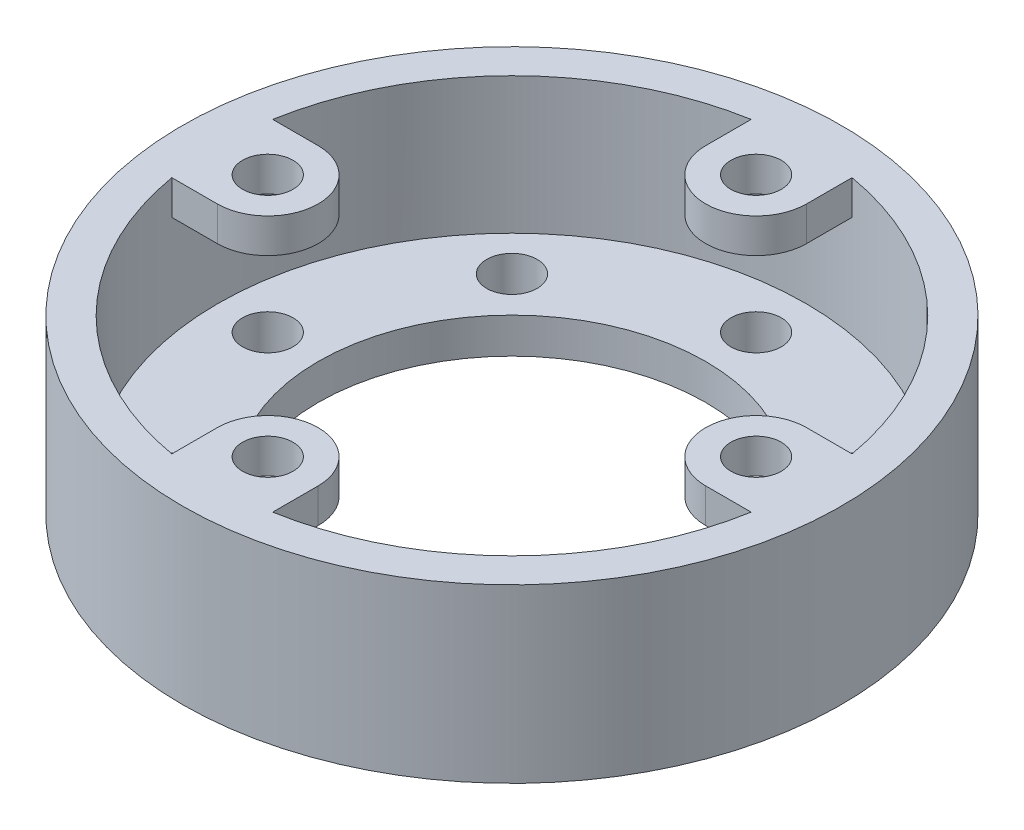
from build123d import *

# Parameters (mm, degrees)
SKETCH1_W           = 7.874
SKETCH1_H           = 38.1
SKETCH2_R           = 65.151
SKETCH2_R_2         = 42.926
BOSS_EXTRUDE2_DEPTH = 7.874
SKETCH4_R           = 5.588
CUT_EXTRUDE1_DEPTH  = 8.874
SKETCH5_R           = 5.588
BOSS_EXTRUDE4_DEPTH = 7.62


with BuildPart() as part:
    # Sketch1 → Revolve1 (revolve)
    with BuildSketch(Plane.XY):
        with Locations((-69.088, 19.05)):
            Rectangle(SKETCH1_W, SKETCH1_H)
    revolve(axis=Axis((0, 92.899450936, 0), (0, -1, 0)))

    # Sketch2 → Boss-Extrude2 (add)
    with BuildSketch(Plane(origin=(0, 0, 0), x_dir=(1, 0, 0), z_dir=(0, 1, 0))):
        Circle(SKETCH2_R)
        Circle(SKETCH2_R_2, mode=Mode.SUBTRACT)
    extrude(amount=BOSS_EXTRUDE2_DEPTH)

    # Sketch4 → Cut-Extrude1 (cut, through all)
    with BuildSketch(Plane(origin=(0, 7.874, 0), x_dir=(1, 0, 0), z_dir=(0, 1, 0))):
        with Locations((0, 54.102)):
            Circle(SKETCH4_R)
        with Locations((38.255891076, 38.255891076)):
            Circle(SKETCH4_R)
        with Locations((54.102, 0)):
            Circle(SKETCH4_R)
        with Locations((38.255891076, -38.255891076)):
            Circle(SKETCH4_R)
        with Locations((0, -54.102)):
            Circle(SKETCH4_R)
        with Locations((-38.255891076, -38.255891076)):
            Circle(SKETCH4_R)
        with Locations((-54.102, 0)):
            Circle(SKETCH4_R)
        with Locations((-38.255891076, 38.255891076)):
            Circle(SKETCH4_R)
    extrude(amount=-CUT_EXTRUDE1_DEPTH, mode=Mode.SUBTRACT)

    # Sketch5 → Boss-Extrude4 (add)
    with BuildSketch(Plane(origin=(0, 38.1, 0), x_dir=(1, 0, 0), z_dir=(0, 1, 0))):
        with BuildLine():
            Line((-54.102, 11.176), (-64.185277323, 11.176))
            ThreePointArc((-64.185277323, 11.176), (-65.151, 0), (-64.185277323, -11.176))
            Line((-64.185277323, -11.176), (-54.102, -11.176))
            ThreePointArc((-54.102, -11.176), (-42.926, 0), (-54.102, 11.176))
        make_face()
        with Locations((-54.102, 0)):
            Circle(SKETCH5_R, mode=Mode.SUBTRACT)
        with BuildLine():
            Line((11.176, 54.102), (11.176, 64.185277323))
            ThreePointArc((11.176, 64.185277323), (0, 65.151), (-11.176, 64.185277323))
            Line((-11.176, 64.185277323), (-11.176, 54.102))
            ThreePointArc((-11.176, 54.102), (0, 42.926), (11.176, 54.102))
        make_face()
        with Locations((0, 54.102)):
            Circle(SKETCH5_R, mode=Mode.SUBTRACT)
        with BuildLine():
            ThreePointArc((65.151, 0), (64.909120329, 5.608823323), (64.185277323, 11.176))
            Line((64.185277323, 11.176), (54.102, 11.176))
            ThreePointArc((54.102, 11.176), (42.926, 0), (54.102, -11.176))
            Line((54.102, -11.176), (64.185277323, -11.176))
            ThreePointArc((64.185277323, -11.176), (64.909120329, -5.608823323), (65.151, 0))
        make_face()
        with Locations((54.102, 0)):
            Circle(SKETCH5_R, mode=Mode.SUBTRACT)
        with BuildLine():
            ThreePointArc((-11.176, -64.185277323), (0, -65.151), (11.176, -64.185277323))
            Line((11.176, -64.185277323), (11.176, -54.102))
            ThreePointArc((11.176, -54.102), (0, -42.926), (-11.176, -54.102))
            Line((-11.176, -54.102), (-11.176, -64.185277323))
        make_face()
        with Locations((0, -54.102)):
            Circle(SKETCH5_R, mode=Mode.SUBTRACT)
    extrude(amount=-BOSS_EXTRUDE4_DEPTH)


solid = part.part
